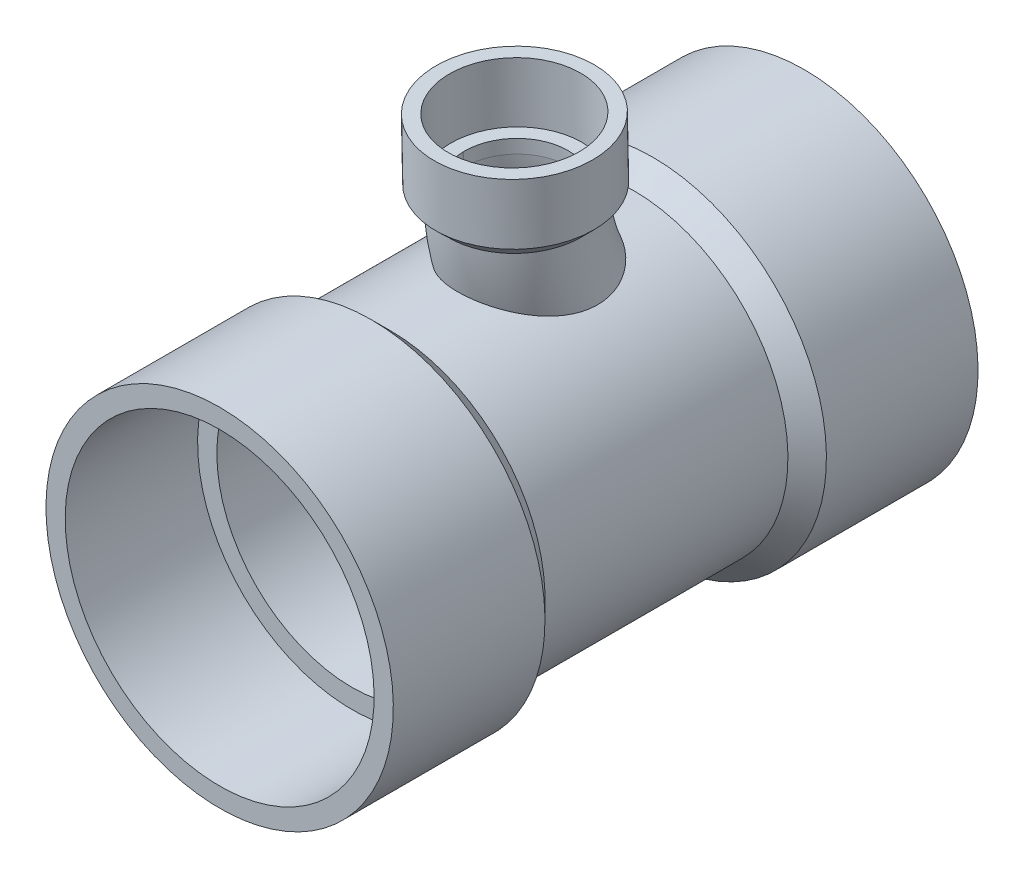
from build123d import *

# Parameters (mm, degrees)
RUNROUTE_R               = 44.45
RUNROUTE_R_2             = 38.9128
BOSS_EXTRUDE1_DEPTH      = 48.41875
BOSS_EXTRUDE1_DEPTH_BACK = 43.65625
OUTLETROUTE_R            = 19.05
OUTLETROUTE_R_2          = 15.0876
RUNROUTE_2_R             = 38.9128
CUT_EXTRUDE1_DEPTH       = 49.4187501
CUT_EXTRUDE1_DEPTH_BACK  = 51.349153098


with BuildPart() as part:
    # RunRoute → Boss-Extrude1 (new body, two sides)
    with BuildSketch(Plane.XY) as boss_extrude1_sk:
        Circle(RUNROUTE_R)
        Circle(RUNROUTE_R_2, mode=Mode.SUBTRACT)
    extrude(amount=BOSS_EXTRUDE1_DEPTH)
    extrude(boss_extrude1_sk.sketch, amount=-BOSS_EXTRUDE1_DEPTH_BACK)

    # Sweep1: sweep along a path in Sketch2
    with BuildLine(Plane(origin=(0, 0, 0), x_dir=(0, 0, -1), z_dir=(1, 0, 0))) as sweep1_path:
        ThreePointArc((-1.330135383, 63.5), (11.421089133, 24.848331737), (43.65625, 0))
    # OutletRoute → Sweep1 (sweep)
    with BuildSketch(Plane(origin=(0, 63.5, 1.330135383), x_dir=(1, 0, 0), z_dir=(0, 0.999780683, 0.02094242))):
        Circle(OUTLETROUTE_R)
        Circle(OUTLETROUTE_R_2, mode=Mode.SUBTRACT)
    sweep(path=sweep1_path.line)

    # RunRoute_2 → Cut-Extrude1 (cut, two sides)
    with BuildSketch(Plane.XY) as cut_extrude1_sk:
        Circle(RUNROUTE_2_R)
    extrude(amount=CUT_EXTRUDE1_DEPTH, mode=Mode.SUBTRACT)
    extrude(cut_extrude1_sk.sketch, amount=-CUT_EXTRUDE1_DEPTH_BACK, mode=Mode.SUBTRACT)

    # Sketch3 → Revolve1 (revolve)
    with BuildSketch(Plane(origin=(0, 0, 0), x_dir=(0, 0, -1), z_dir=(1, 0, 0))):
        Polygon((13.754155657, 63.815970854), (17.715686637, 63.898953099), (17.350245598, 81.344926069), (21.311776579, 81.427908314), (21.680489514, 63.825736638), (17.954867586, 59.940694015), (13.837137901, 59.854439874), align=None)
    revolve(axis=Axis((0, 63.5, 1.330135383), (0, 0.999780683, 0.02094242)))

    # Sketch3_5 → Revolve2 (revolve)
    with BuildSketch(Plane(origin=(0, 0, 0), x_dir=(0, 0, -1), z_dir=(1, 0, 0))):
        Polygon((-48.41875, -38.9128), (-48.41875, -44.45), (-86.51875, -44.45), (-86.51875, -49.9872), (-42.88155, -49.9872), (-37.34435, -44.45), (-37.34435, -38.9128), align=None)
        Polygon((43.65625, -38.9128), (43.65625, -44.45), (81.75625, -44.45), (81.75625, -49.9872), (38.11905, -49.9872), (32.58185, -44.45), (32.58185, -38.9128), align=None)
    revolve(axis=Axis((0, 0, 48.41875), (0, 0, 1)))


solid = part.part
